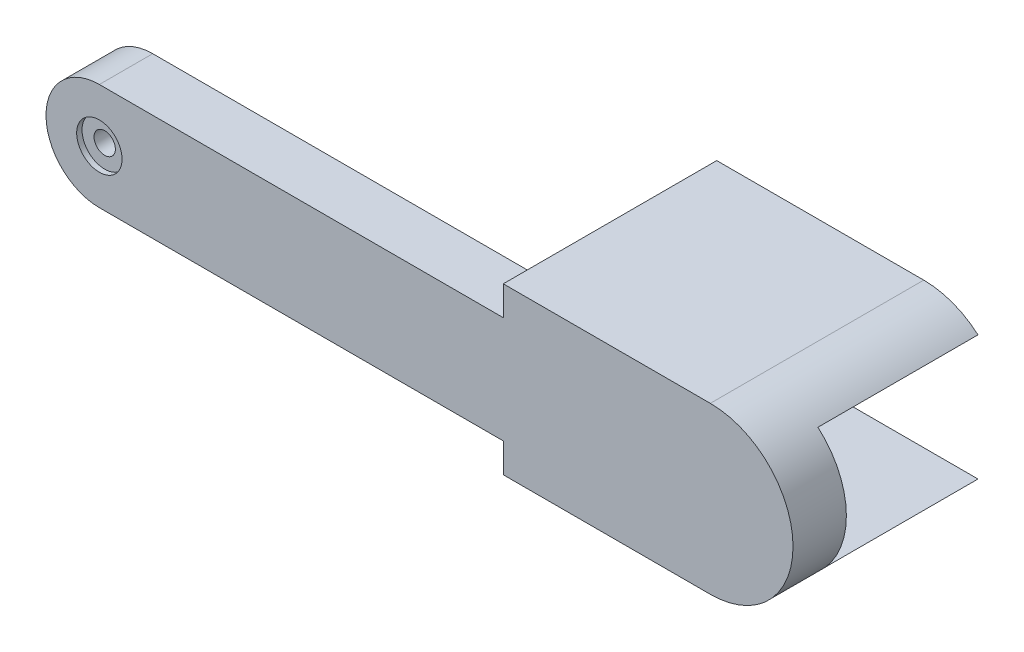
from build123d import *

# Parameters (mm, degrees)
BOSS_EXTRUDE1_DEPTH = 5
CUT_EXTRUDE1_DEPTH  = 3
SKETCH3_R           = 2.125
CUT_EXTRUDE2_DEPTH  = 0.5
SKETCH4_R           = 1
CUT_EXTRUDE3_DEPTH  = 5.5
BOSS_EXTRUDE2_DEPTH = 5
BOSS_EXTRUDE3_DEPTH = 15
SKETCH10_R          = 0.875
CUT_EXTRUDE6_DEPTH  = 6


with BuildPart() as part:
    # Sketch1 → Boss-Extrude1 (new body)
    with BuildSketch(Plane.XY):
        with BuildLine():
            Line((0, 5), (60, 5))
            ThreePointArc((60, 5), (65, 0), (60, -5))
            Line((60, -5), (0, -5))
            ThreePointArc((0, -5), (-5, 0), (0, 5))
        make_face()
    extrude(amount=BOSS_EXTRUDE1_DEPTH)

    # Sketch2 → Cut-Extrude1 (cut)
    with BuildSketch(Plane(origin=(0, 0, 0), x_dir=(-1, 0, 0), z_dir=(0, 0, -1))):
        with BuildLine():
            Line((2.344315233, -0.163358775), (2.25, 0))
            Line((2.25, 0), (2.344315233, 0.163358775))
            ThreePointArc((2.344315233, 0.163358775), (2.3210676, 0.367620993), (2.280056916, 0.56906982))
            Line((2.280056916, 0.56906982), (2.139877162, 0.695288237))
            Line((2.139877162, 0.695288237), (2.179095641, 0.879796675))
            ThreePointArc((2.179095641, 0.879796675), (2.093865332, 1.066877674), (1.992610742, 1.245793895))
            Line((1.992610742, 1.245793895), (1.820288237, 1.322516818))
            Line((1.820288237, 1.322516818), (1.800570985, 1.510113946))
            ThreePointArc((1.800570985, 1.510113946), (1.661700936, 1.661700936), (1.510113946, 1.800570985))
            Line((1.510113946, 1.800570985), (1.322516818, 1.820288237))
            Line((1.322516818, 1.820288237), (1.245793895, 1.992610742))
            ThreePointArc((1.245793895, 1.992610742), (1.066877674, 2.093865332), (0.879796675, 2.179095641))
            Line((0.879796675, 2.179095641), (0.695288237, 2.139877162))
            Line((0.695288237, 2.139877162), (0.56906982, 2.280056916))
            ThreePointArc((0.56906982, 2.280056916), (0.367620993, 2.3210676), (0.163358775, 2.344315233))
            Line((0.163358775, 2.344315233), (0, 2.25))
            Line((0, 2.25), (-0.163358775, 2.344315233))
            ThreePointArc((-0.163358775, 2.344315233), (-0.367620993, 2.3210676), (-0.56906982, 2.280056916))
            Line((-0.56906982, 2.280056916), (-0.695288237, 2.139877162))
            Line((-0.695288237, 2.139877162), (-0.879796675, 2.179095641))
            ThreePointArc((-0.879796675, 2.179095641), (-1.066877674, 2.093865332), (-1.245793895, 1.992610742))
            Line((-1.245793895, 1.992610742), (-1.322516818, 1.820288237))
            Line((-1.322516818, 1.820288237), (-1.510113946, 1.800570985))
            ThreePointArc((-1.510113946, 1.800570985), (-1.661700936, 1.661700936), (-1.800570985, 1.510113946))
            Line((-1.800570985, 1.510113946), (-1.820288237, 1.322516818))
            Line((-1.820288237, 1.322516818), (-1.992610742, 1.245793895))
            ThreePointArc((-1.992610742, 1.245793895), (-2.093865332, 1.066877674), (-2.179095641, 0.879796675))
            Line((-2.179095641, 0.879796675), (-2.139877162, 0.695288237))
            Line((-2.139877162, 0.695288237), (-2.280056916, 0.56906982))
            ThreePointArc((-2.280056916, 0.56906982), (-2.3210676, 0.367620993), (-2.344315233, 0.163358775))
            Line((-2.344315233, 0.163358775), (-2.25, 0))
            Line((-2.25, 0), (-2.344315233, -0.163358775))
            ThreePointArc((-2.344315233, -0.163358775), (-2.3210676, -0.367620993), (-2.280056916, -0.56906982))
            Line((-2.280056916, -0.56906982), (-2.139877162, -0.695288237))
            Line((-2.139877162, -0.695288237), (-2.179095641, -0.879796675))
            ThreePointArc((-2.179095641, -0.879796675), (-2.093865332, -1.066877674), (-1.992610742, -1.245793895))
            Line((-1.992610742, -1.245793895), (-1.820288237, -1.322516818))
            Line((-1.820288237, -1.322516818), (-1.800570985, -1.510113946))
            ThreePointArc((-1.800570985, -1.510113946), (-1.661700936, -1.661700936), (-1.510113946, -1.800570985))
            Line((-1.510113946, -1.800570985), (-1.322516818, -1.820288237))
            Line((-1.322516818, -1.820288237), (-1.245793895, -1.992610742))
            ThreePointArc((-1.245793895, -1.992610742), (-1.066877674, -2.093865332), (-0.879796675, -2.179095641))
            Line((-0.879796675, -2.179095641), (-0.695288237, -2.139877162))
            Line((-0.695288237, -2.139877162), (-0.56906982, -2.280056916))
            ThreePointArc((-0.56906982, -2.280056916), (-0.367620993, -2.3210676), (-0.163358775, -2.344315233))
            Line((-0.163358775, -2.344315233), (0, -2.25))
            Line((0, -2.25), (0.163358775, -2.344315233))
            ThreePointArc((0.163358775, -2.344315233), (0.367620993, -2.3210676), (0.56906982, -2.280056916))
            Line((0.56906982, -2.280056916), (0.695288237, -2.139877162))
            Line((0.695288237, -2.139877162), (0.879796675, -2.179095641))
            ThreePointArc((0.879796675, -2.179095641), (1.066877674, -2.093865332), (1.245793895, -1.992610742))
            Line((1.245793895, -1.992610742), (1.322516818, -1.820288237))
            Line((1.322516818, -1.820288237), (1.510113946, -1.800570985))
            ThreePointArc((1.510113946, -1.800570985), (1.661700936, -1.661700936), (1.800570985, -1.510113946))
            Line((1.800570985, -1.510113946), (1.820288237, -1.322516818))
            Line((1.820288237, -1.322516818), (1.992610742, -1.245793895))
            ThreePointArc((1.992610742, -1.245793895), (2.093865332, -1.066877674), (2.179095641, -0.879796675))
            Line((2.179095641, -0.879796675), (2.139877162, -0.695288237))
            Line((2.139877162, -0.695288237), (2.280056916, -0.56906982))
            ThreePointArc((2.280056916, -0.56906982), (2.3210676, -0.367620993), (2.344315233, -0.163358775))
        make_face()
    extrude(amount=-CUT_EXTRUDE1_DEPTH, mode=Mode.SUBTRACT)

    # Sketch3 → Cut-Extrude2 (cut)
    with BuildSketch(Plane.XY.offset(5)):
        Circle(SKETCH3_R)
    extrude(amount=-CUT_EXTRUDE2_DEPTH, mode=Mode.SUBTRACT)

    # Sketch4 → Cut-Extrude3 (cut, through all)
    with BuildSketch(Plane.XY.offset(4.5)):
        Circle(SKETCH4_R)
    extrude(amount=-CUT_EXTRUDE3_DEPTH, mode=Mode.SUBTRACT)

    # Sketch5 → Boss-Extrude2 (add)
    with BuildSketch(Plane(origin=(0, 0, 0), x_dir=(-1, 0, 0), z_dir=(0, 0, -1))):
        with BuildLine():
            Line((-60, 5), (-37.85, 5))
            Line((-37.85, 5), (-37.85, 7.75))
            Line((-37.85, 7.75), (-57.25, 7.75))
            ThreePointArc((-57.25, 7.75), (-62.730077554, 5.480077554), (-65, 0))
            ThreePointArc((-65, 0), (-63.535533906, 3.535533906), (-60, 5))
        make_face()
        with BuildLine():
            ThreePointArc((-60, -5), (-63.535533906, -3.535533906), (-65, 0))
            ThreePointArc((-65, 0), (-62.730077554, -5.480077554), (-57.25, -7.75))
            Line((-57.25, -7.75), (-37.85, -7.75))
            Line((-37.85, -7.75), (-37.85, -5))
            Line((-37.85, -5), (-60, -5))
        make_face()
    extrude(amount=-BOSS_EXTRUDE2_DEPTH)

    # Sketch6 → Boss-Extrude3 (add)
    with BuildSketch(Plane(origin=(0, 0, 0), x_dir=(-1, 0, 0), z_dir=(0, 0, -1))):
        with BuildLine():
            Line((-62.333306011, -5.85), (-41.85, -5.85))
            Line((-41.85, -5.85), (-41.85, 5.85))
            Line((-41.85, 5.85), (-62.333306011, 5.85))
            ThreePointArc((-62.333306011, 5.85), (-59.96339271, 7.259476565), (-57.25, 7.75))
            Line((-57.25, 7.75), (-37.85, 7.75))
            Line((-37.85, 7.75), (-37.85, 5))
            Line((-37.85, 5), (-37.85, -5))
            Line((-37.85, -5), (-37.85, -7.75))
            Line((-37.85, -7.75), (-57.25, -7.75))
            ThreePointArc((-57.25, -7.75), (-59.96339271, -7.259476565), (-62.333306011, -5.85))
        make_face()
    extrude(amount=BOSS_EXTRUDE3_DEPTH)

    # Sketch10 → Cut-Extrude6 (cut)
    with BuildSketch(Plane(origin=(0, 0, -15), x_dir=(-1, 0, 0), z_dir=(0, 0, -1))):
        with Locations((-39.9, 0)):
            Circle(SKETCH10_R)
    extrude(amount=-CUT_EXTRUDE6_DEPTH, mode=Mode.SUBTRACT)


solid = part.part
